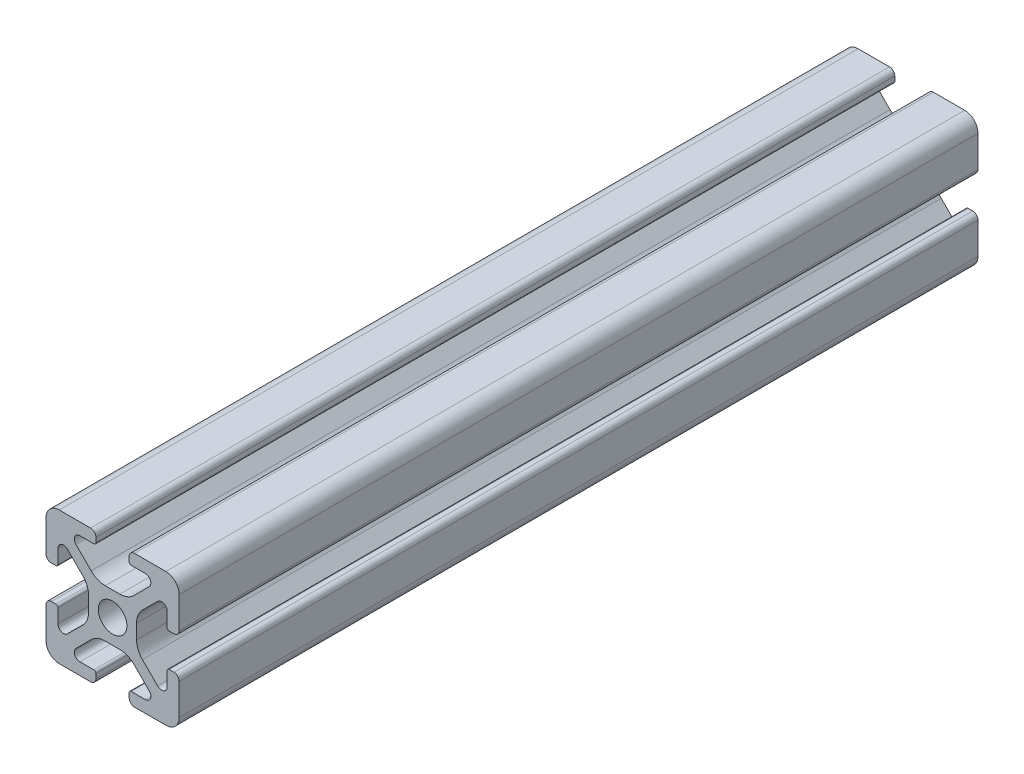
from build123d import *

# Parameters (mm, degrees)
SKETCH3_R           = 2.15
BOSS_EXTRUDE1_DEPTH = 120


with BuildPart() as part:
    # Sketch3 → Boss-Extrude1 (new body)
    with BuildSketch(Plane.XY):
        with BuildLine():
            Line((3.2874, 10), (8, 10))
            ThreePointArc((8, 10), (9.414213562, 9.414213562), (10, 8))
            Line((10, 8), (10, 3.2874))
            ThreePointArc((10, 3.2874), (9.76937588, 2.73062412), (9.2126, 2.5))
            Line((9.2126, 2.5), (8.5048, 2.5))
            ThreePointArc((8.5048, 2.5), (8.289273853, 2.589273853), (8.2, 2.8048))
            Line((8.2, 2.8048), (8.2, 4.9118))
            ThreePointArc((8.2, 4.9118), (7.682565253, 5.686195824), (6.769103096, 5.504496904))
            Line((6.769103096, 5.504496904), (4.478679656, 3.214073464))
            ThreePointArc((4.478679656, 3.214073464), (3.828361402, 2.240803418), (3.6, 1.092753121))
            Line((3.6, 1.092753121), (3.6, -1.092753121))
            ThreePointArc((3.6, -1.092753121), (3.828361402, -2.240803418), (4.478679656, -3.214073464))
            Line((4.478679656, -3.214073464), (6.769103096, -5.504496904))
            ThreePointArc((6.769103096, -5.504496904), (7.682565253, -5.686195824), (8.2, -4.9118))
            Line((8.2, -4.9118), (8.2, -2.8048))
            ThreePointArc((8.2, -2.8048), (8.289273853, -2.589273853), (8.5048, -2.5))
            Line((8.5048, -2.5), (9.2126, -2.5))
            ThreePointArc((9.2126, -2.5), (9.76937588, -2.73062412), (10, -3.2874))
            Line((10, -3.2874), (10, -8))
            ThreePointArc((10, -8), (9.414213562, -9.414213562), (8, -10))
            Line((8, -10), (3.2874, -10))
            ThreePointArc((3.2874, -10), (2.73062412, -9.76937588), (2.5, -9.2126))
            Line((2.5, -9.2126), (2.5, -8.5048))
            ThreePointArc((2.5, -8.5048), (2.589273853, -8.289273853), (2.8048, -8.2))
            Line((2.8048, -8.2), (4.9118, -8.2))
            ThreePointArc((4.9118, -8.2), (5.686195824, -7.682565253), (5.504496904, -6.769103096))
            Line((5.504496904, -6.769103096), (3.214073464, -4.478679656))
            ThreePointArc((3.214073464, -4.478679656), (2.240803418, -3.828361402), (1.092753121, -3.6))
            Line((1.092753121, -3.6), (-1.092753121, -3.6))
            ThreePointArc((-1.092753121, -3.6), (-2.240803418, -3.828361402), (-3.214073464, -4.478679656))
            Line((-3.214073464, -4.478679656), (-5.504496904, -6.769103096))
            ThreePointArc((-5.504496904, -6.769103096), (-5.686195824, -7.682565253), (-4.9118, -8.2))
            Line((-4.9118, -8.2), (-2.8048, -8.2))
            ThreePointArc((-2.8048, -8.2), (-2.589273853, -8.289273853), (-2.5, -8.5048))
            Line((-2.5, -8.5048), (-2.5, -9.2126))
            ThreePointArc((-2.5, -9.2126), (-2.73062412, -9.76937588), (-3.2874, -10))
            Line((-3.2874, -10), (-8, -10))
            ThreePointArc((-8, -10), (-9.414213562, -9.414213562), (-10, -8))
            Line((-10, -8), (-10, -3.2874))
            ThreePointArc((-10, -3.2874), (-9.76937588, -2.73062412), (-9.2126, -2.5))
            Line((-9.2126, -2.5), (-8.5048, -2.5))
            ThreePointArc((-8.5048, -2.5), (-8.289273853, -2.589273853), (-8.2, -2.8048))
            Line((-8.2, -2.8048), (-8.2, -4.9118))
            ThreePointArc((-8.2, -4.9118), (-7.682565253, -5.686195824), (-6.769103096, -5.504496904))
            Line((-6.769103096, -5.504496904), (-4.478679656, -3.214073464))
            ThreePointArc((-4.478679656, -3.214073464), (-3.828361402, -2.240803418), (-3.6, -1.092753121))
            Line((-3.6, -1.092753121), (-3.6, 1.092753121))
            ThreePointArc((-3.6, 1.092753121), (-3.828361402, 2.240803418), (-4.478679656, 3.214073464))
            Line((-4.478679656, 3.214073464), (-6.769103096, 5.504496904))
            ThreePointArc((-6.769103096, 5.504496904), (-7.682565253, 5.686195824), (-8.2, 4.9118))
            Line((-8.2, 4.9118), (-8.2, 2.8048))
            ThreePointArc((-8.2, 2.8048), (-8.289273853, 2.589273853), (-8.5048, 2.5))
            Line((-8.5048, 2.5), (-9.2126, 2.5))
            ThreePointArc((-9.2126, 2.5), (-9.76937588, 2.73062412), (-10, 3.2874))
            Line((-10, 3.2874), (-10, 8))
            ThreePointArc((-10, 8), (-9.414213562, 9.414213562), (-8, 10))
            Line((-8, 10), (-3.2874, 10))
            ThreePointArc((-3.2874, 10), (-2.73062412, 9.76937588), (-2.5, 9.2126))
            Line((-2.5, 9.2126), (-2.5, 8.5048))
            ThreePointArc((-2.5, 8.5048), (-2.589273853, 8.289273853), (-2.8048, 8.2))
            Line((-2.8048, 8.2), (-4.9118, 8.2))
            ThreePointArc((-4.9118, 8.2), (-5.686195824, 7.682565253), (-5.504496904, 6.769103096))
            Line((-5.504496904, 6.769103096), (-3.214073464, 4.478679656))
            ThreePointArc((-3.214073464, 4.478679656), (-2.240803418, 3.828361402), (-1.092753121, 3.6))
            Line((-1.092753121, 3.6), (1.092753121, 3.6))
            ThreePointArc((1.092753121, 3.6), (2.240803418, 3.828361402), (3.214073464, 4.478679656))
            Line((3.214073464, 4.478679656), (5.504496904, 6.769103096))
            ThreePointArc((5.504496904, 6.769103096), (5.686195824, 7.682565253), (4.9118, 8.2))
            Line((4.9118, 8.2), (2.8048, 8.2))
            ThreePointArc((2.8048, 8.2), (2.589273853, 8.289273853), (2.5, 8.5048))
            Line((2.5, 8.5048), (2.5, 9.2126))
            ThreePointArc((2.5, 9.2126), (2.73062412, 9.76937588), (3.2874, 10))
        make_face()
        Circle(SKETCH3_R, mode=Mode.SUBTRACT)
    extrude(amount=BOSS_EXTRUDE1_DEPTH)


solid = part.part
